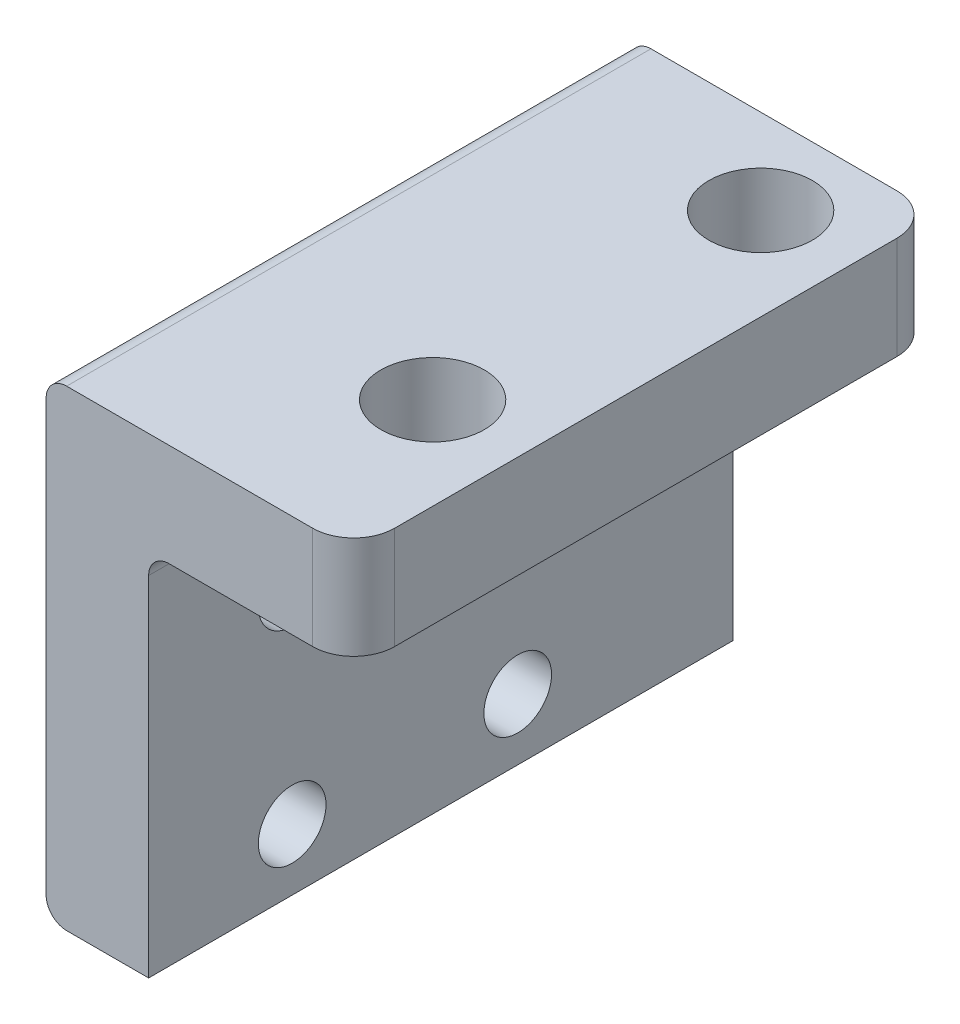
from build123d import *

# Parameters (mm, degrees)
EXTRUDE_1_DEPTH     = 28.5
HOLE_WIZARD_M4_1_D  = 3.3
FILLET_1_R          = 2
SKETCH_4_R          = 2.525
CUT_EXTRUDE_1_DEPTH = 10
FILLET_2_R          = 1


with BuildPart() as part:
    # 草图1 → 凸台-拉伸1 (new body)
    with BuildSketch(Plane.XY):
        Polygon((0, 0), (10, 0), (10, 5), (-5, 5), (-5, -18), (0, -18), align=None)
    extrude(amount=EXTRUDE_1_DEPTH)

    # M4 螺纹孔1 (through all)
    with Locations(Plane(origin=(0, -5, 21.5), x_dir=(0, 1, 0), z_dir=(1, 0, 0))):
        with Locations((0, 0), (-10, 0), (-10, -11), (0, -11)):
            Hole(HOLE_WIZARD_M4_1_D / 2)

    # 圆角1
    fillet_1_edges = [part.edges().sort_by_distance(p)[0] for p in [
        (10, 2.5, 28.5),
        (10, 2.5, 0),
    ]]
    fillet(fillet_1_edges, radius=FILLET_1_R)

    # 草图4 → 切除-拉伸1 (cut)
    with BuildSketch(Plane(origin=(0, 5, 0), x_dir=(1, 0, 0), z_dir=(0, 1, 0))):
        with Locations((5.5, -20.15)):
            Circle(SKETCH_4_R)
        with Locations((5.5, -4.15)):
            Circle(SKETCH_4_R)
    extrude(amount=-CUT_EXTRUDE_1_DEPTH, mode=Mode.SUBTRACT)

    # 圆角2
    fillet_2_edges = [part.edges().sort_by_distance(p)[0] for p in [
        (-5, -18, 14.25),
        (-5, 5, 14.25),
        (0, 0, 14.25),
    ]]
    fillet(fillet_2_edges, radius=FILLET_2_R)


solid = part.part
